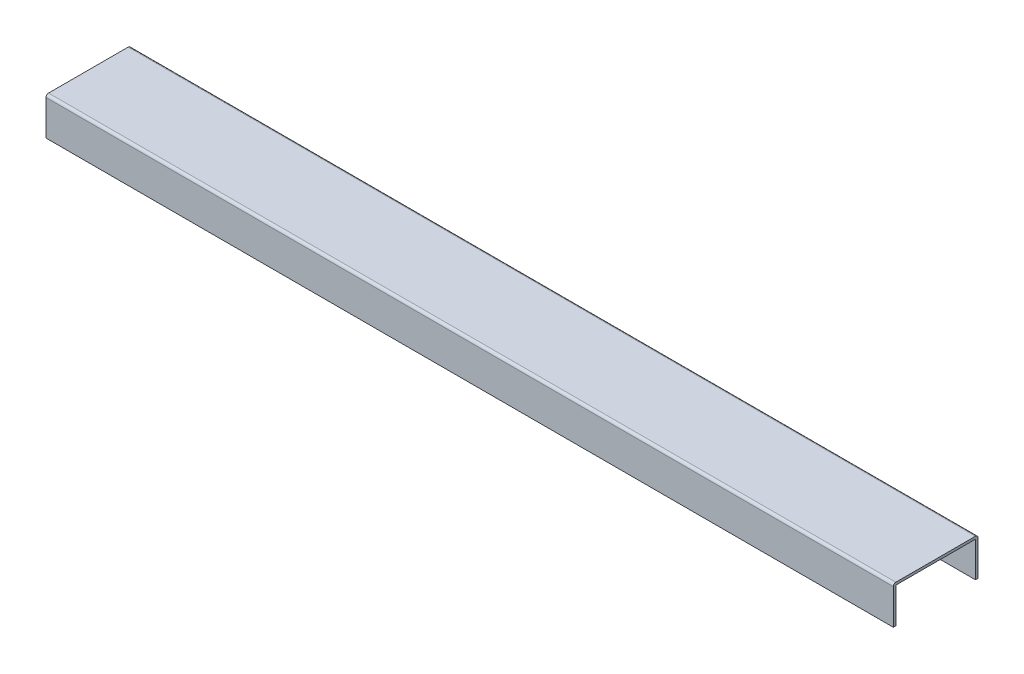
from build123d import *

# Parameters (mm, degrees)
SKETCH_1_W          = 94
SKETCH_1_H          = 94
EXTRUDE_1_DEPTH     = 1000
SKETCH_2_W          = 1000
SKETCH_2_H          = 55.462002837
CUT_EXTRUDE_1_DEPTH = 101


with BuildPart() as part:
    # Эскиз1 → Вытянуть-Тонкостенный1 (new body)
    with BuildSketch(Plane(origin=(0, 0, 0), x_dir=(0, 0, -1), z_dir=(1, 0, 0))):
        with BuildLine():
            Line((0, 97), (0, 3))
            ThreePointArc((0, 3), (0.878679656, 0.878679656), (3, 0))
            Line((3, 0), (97, 0))
            ThreePointArc((97, 0), (99.121320344, 0.878679656), (100, 3))
            Line((100, 3), (100, 97))
            ThreePointArc((100, 97), (99.121320344, 99.121320344), (97, 100))
            Line((97, 100), (3, 100))
            ThreePointArc((3, 100), (0.878679656, 99.121320344), (0, 97))
        make_face()
        with Locations((50, 50)):
            Rectangle(SKETCH_1_W, SKETCH_1_H, mode=Mode.SUBTRACT)
    extrude(amount=EXTRUDE_1_DEPTH)

    # Эскиз2 → Вырез-Вытянуть1 (cut, through all)
    with BuildSketch(Plane(origin=(0, 0, -100), x_dir=(-1, 0, 0), z_dir=(0, 0, -1))):
        with Locations((-500, 27.731001418)):
            Rectangle(SKETCH_2_W, SKETCH_2_H)
    extrude(amount=-CUT_EXTRUDE_1_DEPTH, mode=Mode.SUBTRACT)


solid = part.part
